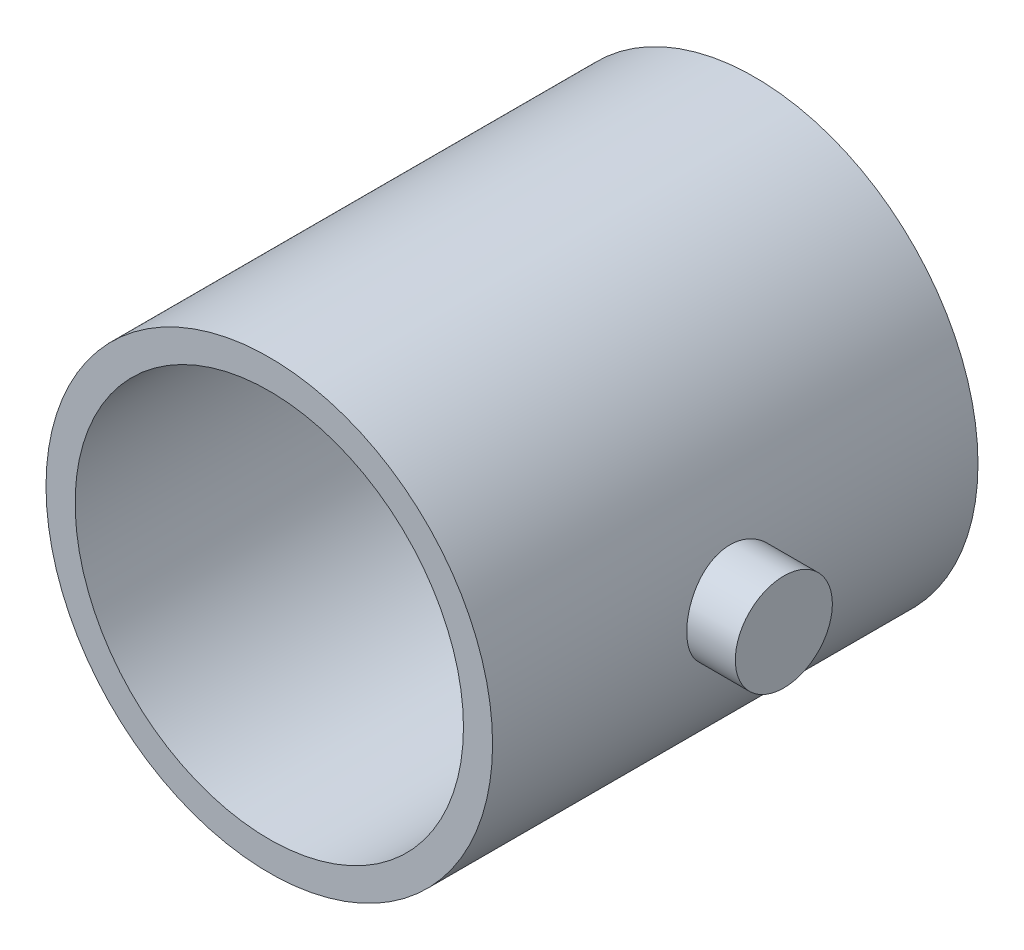
from build123d import *

# Parameters (mm, degrees)
ESQUISSE1_R                    = 23
ESQUISSE1_R_2                  = 20
BOSS_EXTRU_1_DEPTH             = 25
BOSS_EXTRU_2_REACH             = 59.184
BOSS_EXTRU_2_END_RADIUS        = 23
ESQUISSE2_R                    = 5
BOSS_EXTRU_2_DIRECTION_2_DEPTH = 5


with BuildPart() as part:
    # Esquisse1 → Boss.-Extru.1 (new, symmetric)
    with BuildSketch(Plane.XY):
        Circle(ESQUISSE1_R)
        Circle(ESQUISSE1_R_2, mode=Mode.SUBTRACT)
    extrude(amount=BOSS_EXTRU_1_DEPTH, both=True)

    # Boss.-Extru.2: up to this cylinder (the profile starts outside it)
    boss_extru_2_end = Plane(origin=(0, 0, 0), z_dir=(0, 0, -1)) * Cylinder(BOSS_EXTRU_2_END_RADIUS, 165.368, mode=Mode.PRIVATE)
    # Esquisse2 → Boss.-Extru.2 (add, up to the surface)
    with BuildSketch(Plane(origin=(23, 0, 0), x_dir=(0, 0, -1), z_dir=(1, 0, 0)), mode=Mode.PRIVATE) as boss_extru_2_sk1:
        Circle(ESQUISSE2_R)
    boss_extru_2_tool1 = extrude(boss_extru_2_sk1.sketch, amount=-BOSS_EXTRU_2_REACH, mode=Mode.PRIVATE) - boss_extru_2_end
    add(boss_extru_2_tool1.solids().sort_by_distance((23, 0, 0))[0])
    add(boss_extru_2_tool1.solids().sort_by_distance((23, 0, 0))[1])

    # Esquisse2 → Boss.-Extru.2 direction 2 (add)
    with BuildSketch(Plane(origin=(23, 0, 0), x_dir=(0, 0, -1), z_dir=(1, 0, 0))):
        Circle(ESQUISSE2_R)
    extrude(amount=BOSS_EXTRU_2_DIRECTION_2_DEPTH)


solid = part.part
